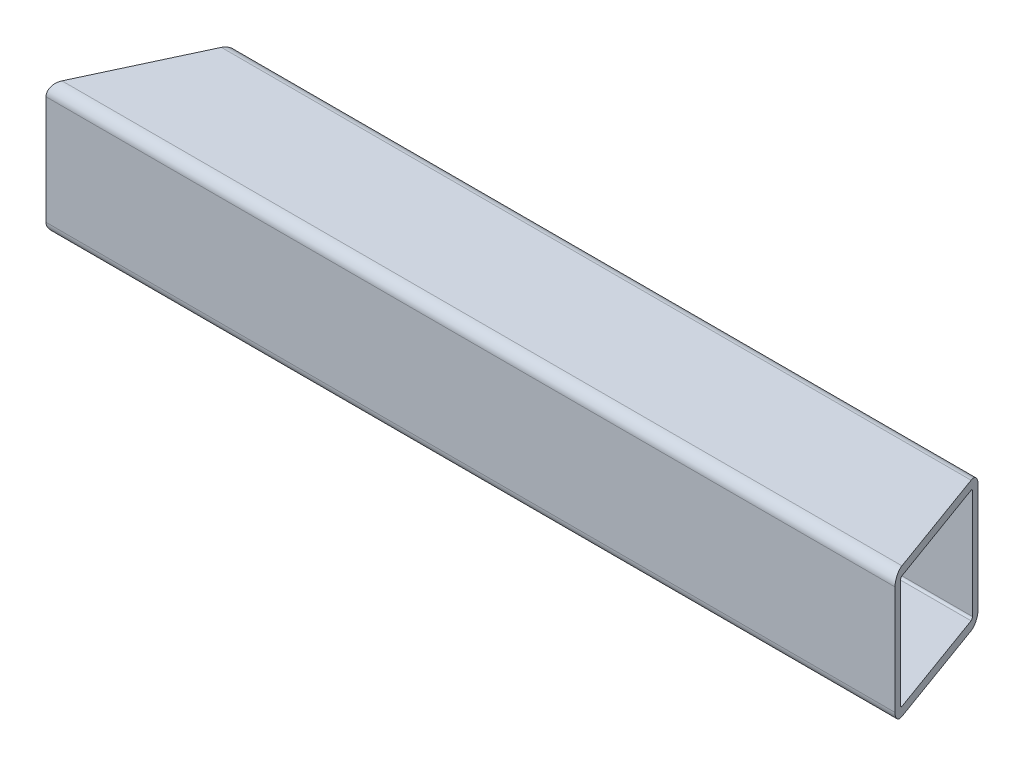
from build123d import *

# Parameters (mm, degrees)
EXTRUDE_THIN1_DEPTH     = 123.98756
CUT_EXTRUDE1_DEPTH      = 1
CUT_EXTRUDE1_DEPTH_BACK = 39.1
CUT_EXTRUDE2_DEPTH      = 1
CUT_EXTRUDE2_DEPTH_BACK = 39.1


with BuildPart() as part:
    # Sketch1 → Extrude-Thin1 (new body, symmetric)
    with BuildSketch(Plane(origin=(0, 0, 0), x_dir=(0, 0, -1), z_dir=(1, 0, 0))):
        with BuildLine():
            Line((-15.875, 19.05), (15.875, 19.05))
            ThreePointArc((15.875, 19.05), (18.12006403, 18.12006403), (19.05, 15.875))
            Line((19.05, 15.875), (19.05, -15.875))
            ThreePointArc((19.05, -15.875), (18.12006403, -18.12006403), (15.875, -19.05))
            Line((15.875, -19.05), (-15.875, -19.05))
            ThreePointArc((-15.875, -19.05), (-18.12006403, -18.12006403), (-19.05, -15.875))
            Line((-19.05, -15.875), (-19.05, 15.875))
            ThreePointArc((-19.05, 15.875), (-18.12006403, 18.12006403), (-15.875, 19.05))
        make_face()
        with BuildLine():
            Line((-15.875, 16.51), (15.875, 16.51))
            ThreePointArc((15.875, 16.51), (16.324012806, 16.324012806), (16.51, 15.875))
            Line((16.51, 15.875), (16.51, -15.875))
            ThreePointArc((16.51, -15.875), (16.324012806, -16.324012806), (15.875, -16.51))
            Line((15.875, -16.51), (-15.875, -16.51))
            ThreePointArc((-15.875, -16.51), (-16.324012806, -16.324012806), (-16.51, -15.875))
            Line((-16.51, -15.875), (-16.51, 15.875))
            ThreePointArc((-16.51, 15.875), (-16.324012806, 16.324012806), (-15.875, 16.51))
        make_face(mode=Mode.SUBTRACT)
    extrude(amount=EXTRUDE_THIN1_DEPTH, both=True)

    # Sketch3 → Cut-Extrude1 (cut, two sides)
    with BuildSketch(Plane(origin=(0, 19.05, 0), x_dir=(1, 0, 0), z_dir=(0, 1, 0))) as cut_extrude1_sk:
        Polygon((299.02319091, -499.956443526), (123.98756, -19.05), (110.120294074, 19.05), (-64.915336836, 499.956443526), (896.897550216, 850.027705346), (1260.836077962, -149.885181705), align=None)
    extrude(amount=CUT_EXTRUDE1_DEPTH, mode=Mode.SUBTRACT)
    extrude(cut_extrude1_sk.sketch, amount=-CUT_EXTRUDE1_DEPTH_BACK, mode=Mode.SUBTRACT)

    # Sketch4 → Cut-Extrude2 (cut, two sides)
    with BuildSketch(Plane(origin=(0, 19.05, 0), x_dir=(1, 0, 0), z_dir=(0, 1, 0))) as cut_extrude2_sk:
        Polygon((-340.270885768, -482.871088899), (-123.98756, -19.05), (-106.221238224, 19.05), (110.062087543, 482.871088899), (-817.580090255, 915.437740434), (-1267.913063566, -50.304437364), align=None)
    extrude(amount=CUT_EXTRUDE2_DEPTH, mode=Mode.SUBTRACT)
    extrude(cut_extrude2_sk.sketch, amount=-CUT_EXTRUDE2_DEPTH_BACK, mode=Mode.SUBTRACT)


solid = part.part
